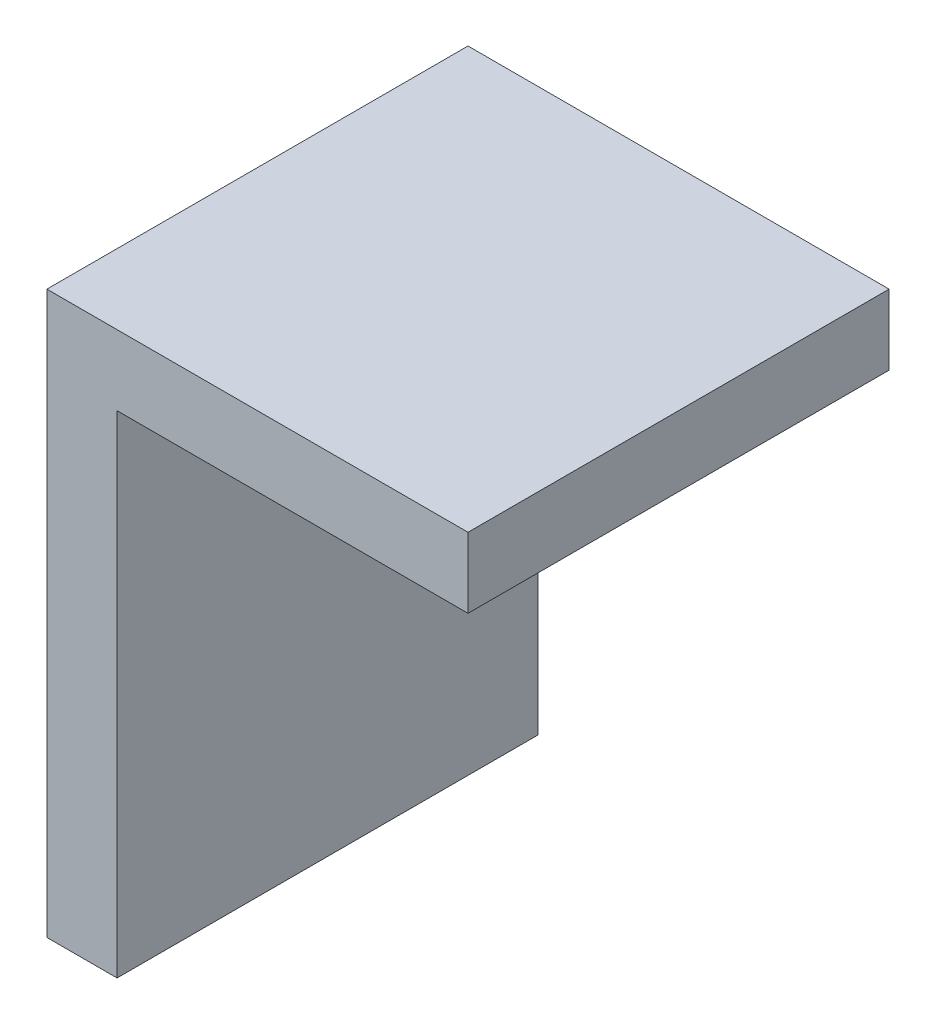
from build123d import *

# Parameters (mm, degrees)
ESQUISSE1_W        = 5
ESQUISSE1_H        = 35
ESQUISSE1_W_2      = 30
ESQUISSE1_H_2      = 5
BOSS_EXTRU_2_DEPTH = 30


with BuildPart() as part:
    # Esquisse1 → Boss.-Extru.2 (new body)
    with BuildSketch(Plane.XY):
        with Locations((-19.519230769, -1.581742196)):
            Rectangle(ESQUISSE1_W, ESQUISSE1_H)
        with Locations((-7.019230769, 18.418257804)):
            Rectangle(ESQUISSE1_W_2, ESQUISSE1_H_2)
    extrude(amount=BOSS_EXTRU_2_DEPTH)


solid = part.part
